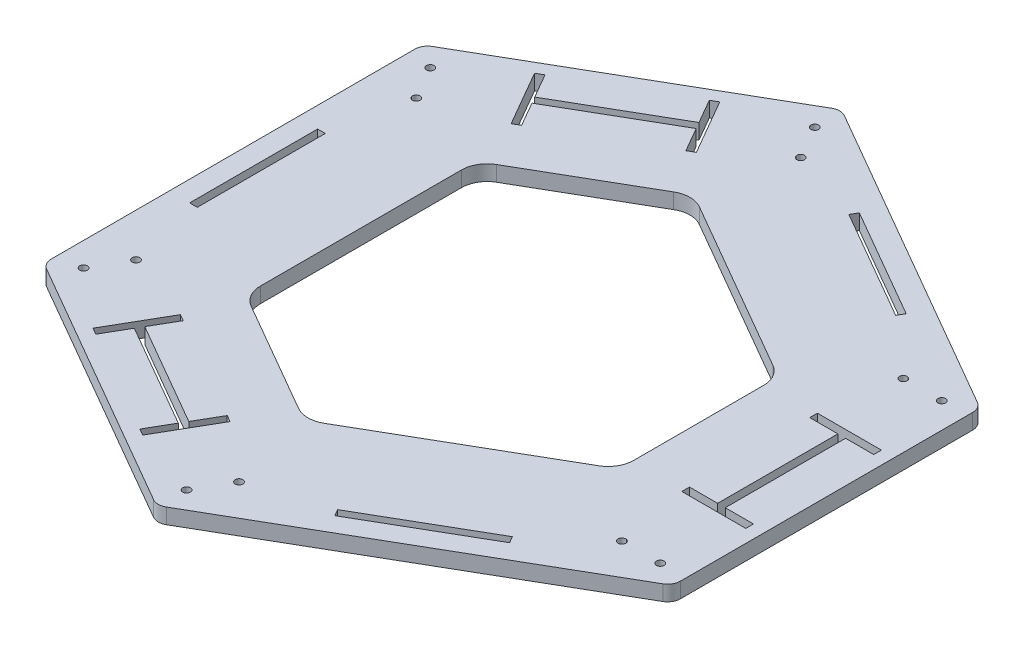
from build123d import *

# Parameters (mm, degrees)
SKETCH6_R           = 1.5
BOSS_EXTRUDE4_DEPTH = 6
CIRPATTERN1_COUNT   = 3
SKETCH8_W           = 3
SKETCH8_H           = 50
CUT_EXTRUDE3_DEPTH  = 7
CUT_EXTRUDE4_DEPTH  = 7
FILLET1_R           = 10
FILLET2_R           = 5
SKETCH9_W           = 25
SKETCH9_H           = 3
CUT_EXTRUDE5_DEPTH  = 7


with BuildPart() as part:
    # Sketch6 → Boss-Extrude4 (new body)
    with BuildSketch(Plane(origin=(0, 0, 0), x_dir=(1, 0, 0), z_dir=(0, 1, 0))):
        Polygon((0, 0), (55.980762114, 96.961524227), (120, 60), (120, -60), (55.980762114, -96.961524227), align=None)
        with Locations((95, 55)):
            Circle(SKETCH6_R, mode=Mode.SUBTRACT)
        with Locations((110, 55)):
            Circle(SKETCH6_R, mode=Mode.SUBTRACT)
        with Locations((95, -55)):
            Circle(SKETCH6_R, mode=Mode.SUBTRACT)
        with Locations((110, -55)):
            Circle(SKETCH6_R, mode=Mode.SUBTRACT)
    boss_extrude4 = extrude(amount=BOSS_EXTRUDE4_DEPTH)

    # CirPattern1: Boss-Extrude4 ×3 about axis
    cirpattern1_axis = Axis((0, 0, 0), (0, 1, 0))
    for i in range(1, CIRPATTERN1_COUNT):
        add(boss_extrude4.rotate(cirpattern1_axis, i * 360 / CIRPATTERN1_COUNT))

    # Sketch8 → Cut-Extrude3 (cut, through all)
    with BuildSketch(Plane(origin=(0, 6, 0), x_dir=(1, 0, 0), z_dir=(0, 1, 0))):
        Polygon((73.612159322, -77.5), (30.310889132, -102.5), (28.810889132, -99.901923789), (72.112159322, -74.901923789), align=None)
        with Locations((102.423048454, 0)):
            Rectangle(SKETCH8_W, SKETCH8_H)
        Polygon((-30.310889132, -102.5), (-73.612159322, -77.5), (-72.112159322, -74.901923789), (-28.810889132, -99.901923789), align=None)
        with Locations((-102.423048454, 0)):
            Rectangle(SKETCH8_W, SKETCH8_H)
        Polygon((-73.612159322, 77.5), (-30.310889132, 102.5), (-28.810889132, 99.901923789), (-72.112159322, 74.901923789), align=None)
        Polygon((30.310889132, 102.5), (73.612159322, 77.5), (72.112159322, 74.901923789), (28.810889132, 99.901923789), align=None)
    extrude(amount=-CUT_EXTRUDE3_DEPTH, mode=Mode.SUBTRACT)

    # Sketch7 → Cut-Extrude4 (cut, through all)
    with BuildSketch(Plane(origin=(0, 6, 0), x_dir=(1, 0, 0), z_dir=(0, 1, 0))):
        Polygon((-61.961524227, 45.055534995), (-61.961524227, -45.055534995), (-8.038475773, -76.188021535), (70, -31.132486541), (70, 31.132486541), (-8.038475773, 76.188021535), align=None)
    extrude(amount=-CUT_EXTRUDE4_DEPTH, mode=Mode.SUBTRACT)

    # Fillet1
    fillet1_edges = [part.edges().sort_by_distance(p)[0] for p in [
        (-61.961524227, 3, -45.055534995),
        (-8.038475773, 3, -76.188021535),
        (70, 3, -31.132486541),
        (70, 3, 31.132486541),
        (-8.038475773, 3, 76.188021535),
        (-61.961524227, 3, 45.055534995),
    ]]
    fillet(fillet1_edges, radius=FILLET1_R)

    # Fillet2
    fillet2_edges = [part.edges().sort_by_distance(p)[0] for p in [
        (-8.038475773, 3, -133.923048454),
        (-111.961524227, 3, -73.923048454),
        (-111.961524227, 3, 73.923048454),
        (-8.038475773, 3, 133.923048454),
        (120, 3, -60),
        (120, 3, 60),
    ]]
    fillet(fillet2_edges, radius=FILLET2_R)

    # Sketch9 → Cut-Extrude5 (cut, through all)
    with BuildSketch(Plane(origin=(0, 6, 0), x_dir=(1, 0, 0), z_dir=(0, 1, 0))):
        with Locations((102.423048454, -25)):
            Rectangle(SKETCH9_W, SKETCH9_H)
        with Locations((102.423048454, 25)):
            Rectangle(SKETCH9_W, SKETCH9_H)
        Polygon((-67.911197427, -64.625644347), (-65.313121216, -66.125644347), (-77.813121216, -87.776279442), (-80.411197427, -86.276279442), align=None)
        Polygon((-24.609927238, -89.625644347), (-22.011851027, -91.125644347), (-34.511851027, -112.776279442), (-37.109927238, -111.276279442), align=None)
        Polygon((-22.011851027, 91.125644347), (-24.609927238, 89.625644347), (-37.109927238, 111.276279442), (-34.511851027, 112.776279442), align=None)
        Polygon((-65.313121216, 66.125644347), (-67.911197427, 64.625644347), (-80.411197427, 86.276279442), (-77.813121216, 87.776279442), align=None)
    extrude(amount=-CUT_EXTRUDE5_DEPTH, mode=Mode.SUBTRACT)


solid = part.part
